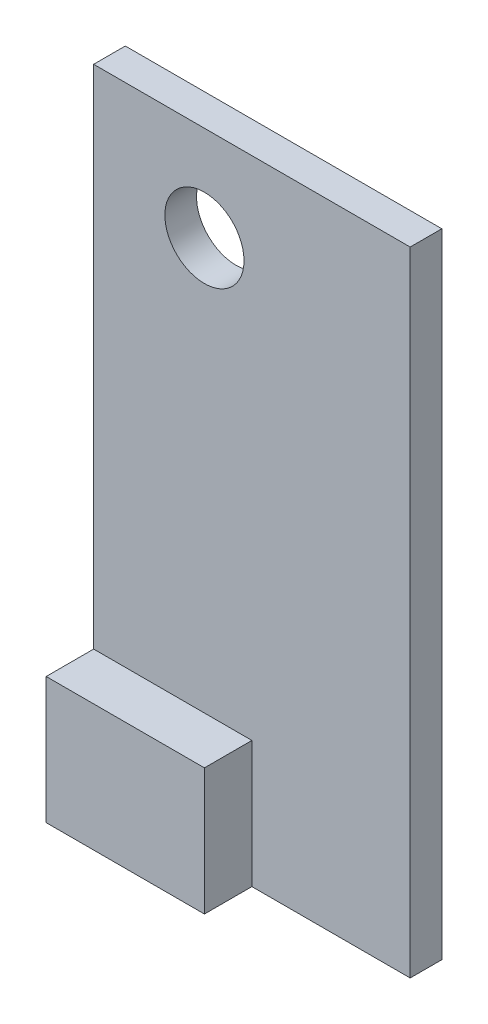
from build123d import *

# Parameters (mm, degrees)
SKETCH2_W           = 100
SKETCH2_H           = 200
BOSS_EXTRUDE1_DEPTH = 10
SKETCH3_W           = 50
SKETCH3_H           = 40
BOSS_EXTRUDE3_DEPTH = 25
SKETCH8_R           = 12.5
CUT_EXTRUDE2_DEPTH  = 26


with BuildPart() as part:
    # Sketch2 → Boss-Extrude1 (new body)
    with BuildSketch(Plane.XY):
        with Locations((50, 100)):
            Rectangle(SKETCH2_W, SKETCH2_H)
    extrude(amount=BOSS_EXTRUDE1_DEPTH)

    # Sketch3 → Boss-Extrude3 (add)
    with BuildSketch(Plane.XY):
        with Locations((25, 20)):
            Rectangle(SKETCH3_W, SKETCH3_H)
    extrude(amount=BOSS_EXTRUDE3_DEPTH)

    # Sketch8 → Cut-Extrude2 (cut, through all)
    with BuildSketch(Plane.XY.offset(25)):
        with Locations((35, 170)):
            Circle(SKETCH8_R)
    extrude(amount=-CUT_EXTRUDE2_DEPTH, mode=Mode.SUBTRACT)


solid = part.part
